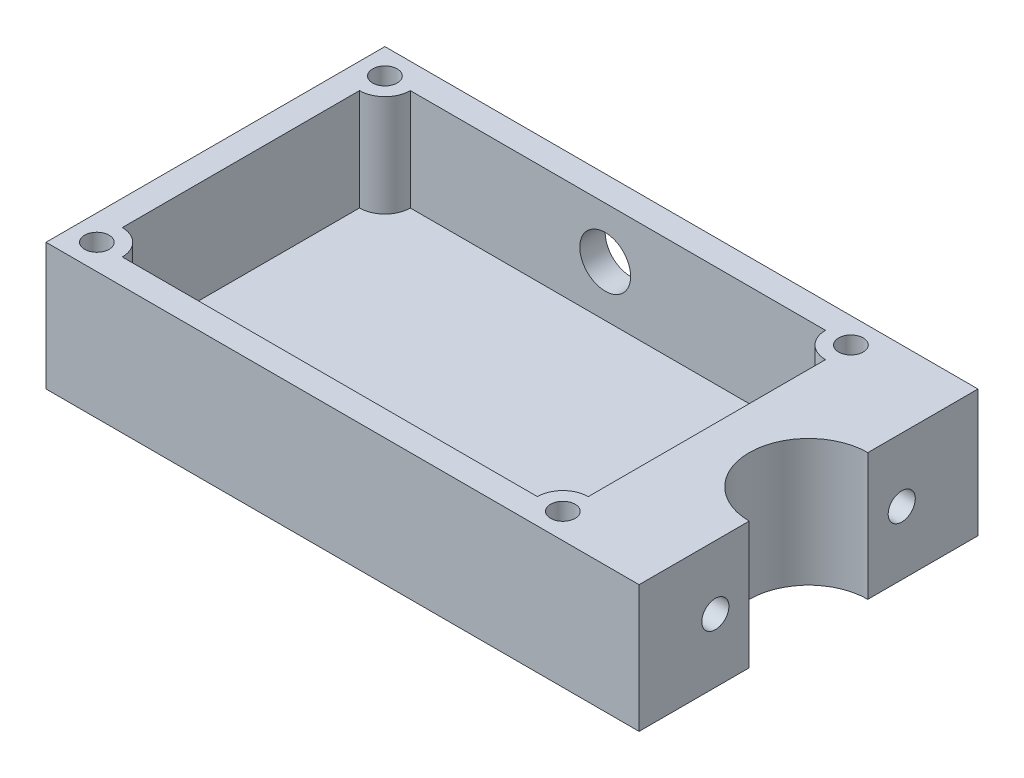
from build123d import *

# Parameters (mm, degrees)
BOSS_EXTRUDE1_DEPTH = 15
SKETCH2_W           = 55
SKETCH2_H           = 34
CUT_EXTRUDE1_DEPTH  = 12
CUT_EXTRUDE2_REACH  = 72
SKETCH4_R           = 1.6
CUT_EXTRUDE3_DEPTH  = 4
BOSS_EXTRUDE3_REACH = 17
SKETCH7_R           = 1.45
CUT_EXTRUDE4_DEPTH  = 16
SKETCH8_R           = 3
CUT_EXTRUDE5_DEPTH  = 4


with BuildPart() as part:
    # Sketch1 → Boss-Extrude1 (new body)
    with BuildSketch(Plane(origin=(0, 0, 0), x_dir=(1, 0, 0), z_dir=(0, 1, 0))):
        with BuildLine():
            Line((35, 20), (35, 7))
            ThreePointArc((35, 7), (28, 0), (35, -7))
            Line((35, -7), (35, -20))
            Line((35, -20), (-35, -20))
            Line((-35, -20), (-35, 20))
            Line((-35, 20), (35, 20))
        make_face()
    extrude(amount=BOSS_EXTRUDE1_DEPTH)

    # Sketch2 → Cut-Extrude1 (cut)
    with BuildSketch(Plane(origin=(0, 15, 0), x_dir=(1, 0, 0), z_dir=(0, 1, 0))):
        with Locations((-4.5, 0)):
            Rectangle(SKETCH2_W, SKETCH2_H)
    extrude(amount=-CUT_EXTRUDE1_DEPTH, mode=Mode.SUBTRACT)

    # Sketch4 → Cut-Extrude2 (cut, up to next)
    with BuildSketch(Plane(origin=(35, 0, 0), x_dir=(0, 0, -1), z_dir=(1, 0, 0)), mode=Mode.PRIVATE) as cut_extrude2_sk1:
        with Locations((11, 7.5)):
            Circle(SKETCH4_R)
    cut_extrude2_tool1 = extrude(cut_extrude2_sk1.sketch, amount=-CUT_EXTRUDE2_REACH, mode=Mode.PRIVATE) & part.part
    add(cut_extrude2_tool1.solids().sort_by_distance((35, 7.5, -11))[0], mode=Mode.SUBTRACT)
    # Sketch4 → Cut-Extrude2 (cut, up to next)
    with BuildSketch(Plane(origin=(35, 0, 0), x_dir=(0, 0, -1), z_dir=(1, 0, 0)), mode=Mode.PRIVATE) as cut_extrude2_sk2:
        with Locations((-11, 7.5)):
            Circle(SKETCH4_R)
    cut_extrude2_tool2 = extrude(cut_extrude2_sk2.sketch, amount=-CUT_EXTRUDE2_REACH, mode=Mode.PRIVATE) & part.part
    add(cut_extrude2_tool2.solids().sort_by_distance((35, 7.5, 11))[0], mode=Mode.SUBTRACT)

    # Sketch5 → Cut-Extrude3 (cut)
    with BuildSketch(Plane.ZY.offset(-23)):
        Polygon((-11, 10.75), (-13.814582562, 9.125), (-13.814582562, 5.875), (-11, 4.25), (-8.185417438, 5.875), (-8.185417438, 9.125), align=None)
        Polygon((8.185417438, 9.125), (8.185417438, 5.875), (11, 4.25), (13.814582562, 5.875), (13.814582562, 9.125), (11, 10.75), align=None)
    extrude(amount=-CUT_EXTRUDE3_DEPTH, mode=Mode.SUBTRACT)

    # Sketch6 → Boss-Extrude3 (add, up to next)
    with BuildSketch(Plane(origin=(0, 15, 0), x_dir=(1, 0, 0), z_dir=(0, 1, 0)), mode=Mode.PRIVATE) as boss_extrude3_sk1:
        with BuildLine():
            Line((-32, -14), (-32, -17))
            Line((-32, -17), (-29, -17))
            ThreePointArc((-29, -17), (-29.878679656, -14.878679656), (-32, -14))
        make_face()
    boss_extrude3_tool1 = extrude(boss_extrude3_sk1.sketch, amount=-BOSS_EXTRUDE3_REACH, mode=Mode.PRIVATE) - part.part
    add(boss_extrude3_tool1.solids().sort_by_distance((-30.72676, 15, 15.72676))[0])
    # Sketch6 → Boss-Extrude3 (add, up to next)
    with BuildSketch(Plane(origin=(0, 15, 0), x_dir=(1, 0, 0), z_dir=(0, 1, 0)), mode=Mode.PRIVATE) as boss_extrude3_sk2:
        with BuildLine():
            Line((23, -14), (23, -17))
            Line((23, -17), (20, -17))
            ThreePointArc((20, -17), (20.878679656, -14.878679656), (23, -14))
        make_face()
    boss_extrude3_tool2 = extrude(boss_extrude3_sk2.sketch, amount=-BOSS_EXTRUDE3_REACH, mode=Mode.PRIVATE) - part.part
    add(boss_extrude3_tool2.solids().sort_by_distance((21.72676, 15, 15.72676))[0])
    # Sketch6 → Boss-Extrude3 (add, up to next)
    with BuildSketch(Plane(origin=(0, 15, 0), x_dir=(1, 0, 0), z_dir=(0, 1, 0)), mode=Mode.PRIVATE) as boss_extrude3_sk3:
        with BuildLine():
            Line((20, 17), (23, 17))
            Line((23, 17), (23, 14))
            ThreePointArc((23, 14), (20.878679656, 14.878679656), (20, 17))
        make_face()
    boss_extrude3_tool3 = extrude(boss_extrude3_sk3.sketch, amount=-BOSS_EXTRUDE3_REACH, mode=Mode.PRIVATE) - part.part
    add(boss_extrude3_tool3.solids().sort_by_distance((21.72676, 15, -15.72676))[0])
    # Sketch6 → Boss-Extrude3 (add, up to next)
    with BuildSketch(Plane(origin=(0, 15, 0), x_dir=(1, 0, 0), z_dir=(0, 1, 0)), mode=Mode.PRIVATE) as boss_extrude3_sk4:
        with BuildLine():
            Line((-32, 14), (-32, 17))
            Line((-32, 17), (-29, 17))
            ThreePointArc((-29, 17), (-29.878679656, 14.878679656), (-32, 14))
        make_face()
    boss_extrude3_tool4 = extrude(boss_extrude3_sk4.sketch, amount=-BOSS_EXTRUDE3_REACH, mode=Mode.PRIVATE) - part.part
    add(boss_extrude3_tool4.solids().sort_by_distance((-30.72676, 15, -15.72676))[0])

    # Sketch7 → Cut-Extrude4 (cut, through all)
    with BuildSketch(Plane(origin=(0, 15, 0), x_dir=(1, 0, 0), z_dir=(0, 1, 0))):
        with Locations((-32, 17)):
            Circle(SKETCH7_R)
        with Locations((23, 17)):
            Circle(SKETCH7_R)
        with Locations((23, -17)):
            Circle(SKETCH7_R)
        with Locations((-32, -17)):
            Circle(SKETCH7_R)
    extrude(amount=-CUT_EXTRUDE4_DEPTH, mode=Mode.SUBTRACT)

    # Sketch8 → Cut-Extrude5 (cut, through all)
    with BuildSketch(Plane.XY.offset(-17)):
        with Locations((-6, 9)):
            Circle(SKETCH8_R)
    extrude(amount=-CUT_EXTRUDE5_DEPTH, mode=Mode.SUBTRACT)


solid = part.part
